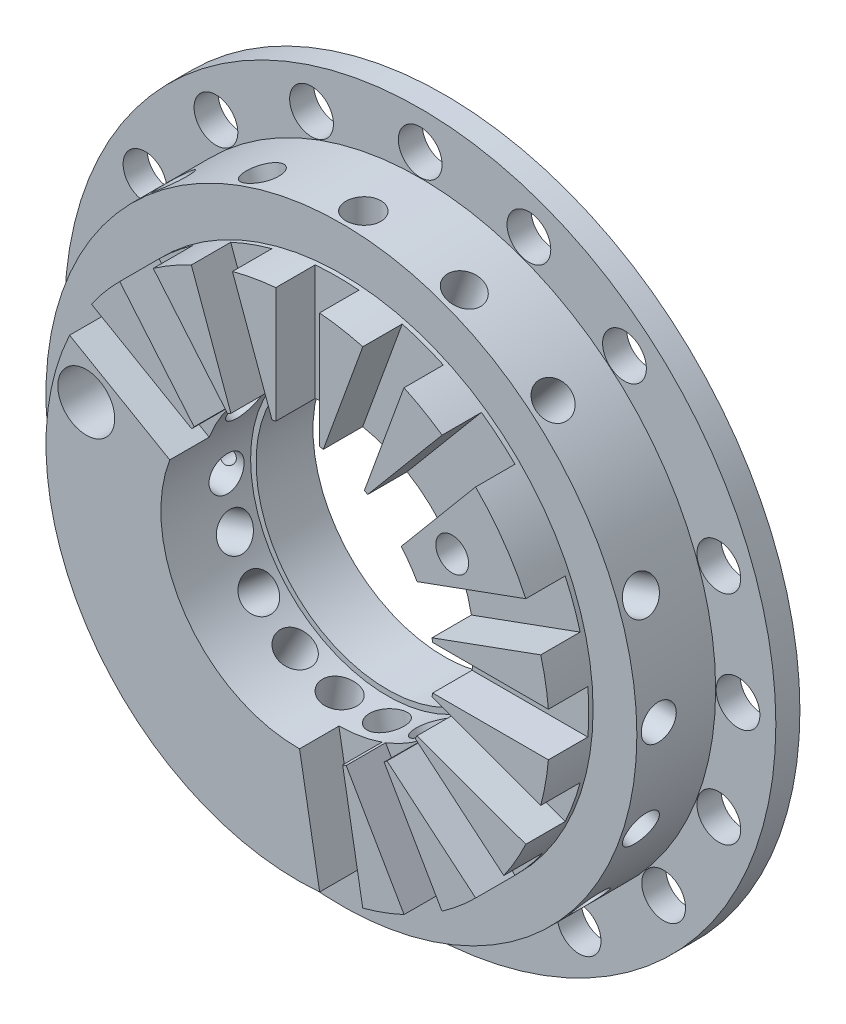
from build123d import *

# Parameters (mm, degrees)
SKETCH1_R                       = 16.25
BOSS_EXTRUDE1_DEPTH             = 6.7
SKETCH2_OUTSIDE_W               = 43.79
SKETCH2_OUTSIDE_H               = 43.79
SKETCH2_OUTSIDE_R               = 13.5
CUT_EXTRUDE1_DEPTH              = 5.6
SKETCH3_OUTSIDE_W               = 43.79
SKETCH3_OUTSIDE_H               = 43.79
SKETCH3_OUTSIDE_R               = 11.5
CUT_EXTRUDE2_DEPTH              = 2
SKETCH4_R                       = 6
CUT_EXTRUDE3_DEPTH              = 24.937731722
SKETCH5_R                       = 6.25
CUT_EXTRUDE4_DEPTH              = 4.1
F_2_0_2_DIAMETER_HOLE1_D        = 2
CUT_EXTRUDE5_DEPTH              = 1.8
CIRPATTERN1_COUNT               = 6
CIRPATTERN1_ANGLE               = 100
CUT_EXTRUDE6_DEPTH              = 1.8
CIRPATTERN2_COUNT               = 6
CIRPATTERN2_ANGLE               = 100
F_1_6_1_6_DIAMETER_HOLE1_REACH  = 36.223
F_1_6_1_6_DIAMETER_HOLE1_BORE_R = 0.8
CIRPATTERN3_COUNT               = 11
CIRPATTERN3_ANGLE               = 200
F_1_6_1_6_DIAMETER_HOLE2_REACH  = 38.494
F_1_6_1_6_DIAMETER_HOLE2_BORE_R = 0.8
CIRPATTERN4_COUNT               = 6
CIRPATTERN4_ANGLE               = 100
F_2_6_2_6_DIAMETER_HOLE1_D      = 2.6
F_1_5_1_5_DIAMETER_HOLE1_D      = 1.5
F_0_8_0_8_DIAMETER_HOLE1_REACH  = 25.938
F_0_8_0_8_DIAMETER_HOLE1_BORE_R = 0.4


with BuildPart() as part:
    # Sketch1 → Boss-Extrude1 (new body)
    with BuildSketch(Plane.XY):
        Circle(SKETCH1_R)
    extrude(amount=BOSS_EXTRUDE1_DEPTH)

    # Sketch2 outside → Cut-Extrude1 (cut)
    with BuildSketch(Plane.XY.offset(6.7)):
        Rectangle(SKETCH2_OUTSIDE_W, SKETCH2_OUTSIDE_H)
        Circle(SKETCH2_OUTSIDE_R, mode=Mode.SUBTRACT)
    extrude(amount=-CUT_EXTRUDE1_DEPTH, mode=Mode.SUBTRACT)

    # Sketch3 outside → Cut-Extrude2 (cut)
    with BuildSketch(Plane.XY.offset(6.7)):
        Rectangle(SKETCH3_OUTSIDE_W, SKETCH3_OUTSIDE_H)
        Circle(SKETCH3_OUTSIDE_R, mode=Mode.SUBTRACT)
    extrude(amount=-CUT_EXTRUDE2_DEPTH, mode=Mode.SUBTRACT)

    # Sketch4 → Cut-Extrude3 (cut, through all)
    with BuildSketch(Plane.XY.offset(6.7)):
        Circle(SKETCH4_R)
    extrude(amount=-CUT_EXTRUDE3_DEPTH, mode=Mode.SUBTRACT)

    # Sketch5 → Cut-Extrude4 (cut)
    with BuildSketch(Plane.XY.offset(6.7)):
        Circle(SKETCH5_R)
    extrude(amount=-CUT_EXTRUDE4_DEPTH, mode=Mode.SUBTRACT)

    # Ø2.0 (2) Diameter Hole1 (through all)
    with Locations(Plane.XY.offset(1.1)):
        with Locations((-9.333276093, 11.122965314), (-4.966132481, 13.644336854), (0, 14.52), (4.966132481, 13.644336854), (9.333276093, 11.122965314), (-13.644336854, -4.966132481), (-11.122965314, -9.333276093), (-7.26, -12.574688863), (-2.52137154, -14.299408574), (2.52137154, -14.299408574), (7.26, -12.574688863), (11.122965314, -9.333276093), (14.52, 0), (13.644336854, 4.966132481), (-14.52, 0), (-12.574688863, 7.26), (13.644336854, -4.966132481)):
            Hole(F_2_0_2_DIAMETER_HOLE1_D / 2)

    # Sketch11 → Cut-Extrude5 (cut)
    with BuildSketch(Plane.XY.offset(6.7)):
        with BuildLine():
            Line((-4.842927568, 3.950766074), (-9.421567416, 6.594245022))
            ThreePointArc((-9.421567416, 6.594245022), (-9.959292144, 5.75), (-10.421567416, 4.862194215))
            Line((-10.421567416, 4.862194215), (-5.842927568, 2.218715266))
            ThreePointArc((-5.842927568, 2.218715266), (-5.412658774, 3.125), (-4.842927568, 3.950766074))
        make_face()
    cut_extrude5 = extrude(amount=-CUT_EXTRUDE5_DEPTH, mode=Mode.SUBTRACT)

    # CirPattern1: Cut-Extrude5 ×6 about axis
    cirpattern1_axis = Axis((0, 0, 0), (0, 0, -1))
    for i in range(1, CIRPATTERN1_COUNT):
        add(cut_extrude5.rotate(cirpattern1_axis, i * CIRPATTERN1_ANGLE / (CIRPATTERN1_COUNT - 1)), mode=Mode.SUBTRACT)

    # Sketch12 → Cut-Extrude6 (cut)
    with BuildSketch(Plane.XY.offset(6.7)):
        with BuildLine():
            Line((6.139436232, 1.170394271), (11.107551555, 2.978640369))
            ThreePointArc((11.107551555, 2.978640369), (10.806465139, 3.933231648), (10.423511269, 4.858025611))
            Line((10.423511269, 4.858025611), (5.455395946, 3.049779513))
            ThreePointArc((5.455395946, 3.049779513), (5.87307888, 2.137625896), (6.139436232, 1.170394271))
        make_face()
    cut_extrude6 = extrude(amount=-CUT_EXTRUDE6_DEPTH, mode=Mode.SUBTRACT)

    # CirPattern2: Cut-Extrude6 ×6 about axis
    cirpattern2_axis = Axis((0, 0, 0), (0, 0, -1))
    for i in range(1, CIRPATTERN2_COUNT):
        add(cut_extrude6.rotate(cirpattern2_axis, i * CIRPATTERN2_ANGLE / (CIRPATTERN2_COUNT - 1)), mode=Mode.SUBTRACT)

    # Ø1.6 (1.6) Diameter Hole1 bore → Ø1.6 (1.6) Diameter Hole1 (cut, up to next)
    with BuildSketch(Plane(origin=(-13.5, 0, 4.7), x_dir=(0, 0, 1), z_dir=(-1, 0, 0)), mode=Mode.PRIVATE) as f_1_6_1_6_diameter_hole1_sk1:
        with Locations((-1, 0)):
            Circle(F_1_6_1_6_DIAMETER_HOLE1_BORE_R)
    f_1_6_1_6_diameter_hole1_tool1 = extrude(f_1_6_1_6_diameter_hole1_sk1.sketch, amount=-F_1_6_1_6_DIAMETER_HOLE1_REACH, mode=Mode.PRIVATE) & part.part
    f_1_6_1_6_diameter_hole1 = f_1_6_1_6_diameter_hole1_tool1.solids().sort_by_distance((-13.5, 0, 3.7))[0]
    add(f_1_6_1_6_diameter_hole1, mode=Mode.SUBTRACT)

    # CirPattern3: Ø1.6 (1.6) Diameter Hole1 ×11 about axis
    cirpattern3_axis = Axis((0, 0, 4.7), (0, 0, 1))
    for i in range(1, CIRPATTERN3_COUNT):
        add(f_1_6_1_6_diameter_hole1.rotate(cirpattern3_axis, i * CIRPATTERN3_ANGLE / (CIRPATTERN3_COUNT - 1)), mode=Mode.SUBTRACT)

    # Ø1.6 (1.6) Diameter Hole2 bore → Ø1.6 (1.6) Diameter Hole2 (cut, up to next)
    with BuildSketch(Plane(origin=(-11.691342951, 6.75, 4.7), x_dir=(0, 0, 1), z_dir=(-0.8660254037844386, 0.5000000000000003, 0)), mode=Mode.PRIVATE) as f_1_6_1_6_diameter_hole2_sk1:
        with Locations((-1, 0)):
            Circle(F_1_6_1_6_DIAMETER_HOLE2_BORE_R)
    f_1_6_1_6_diameter_hole2_tool1 = extrude(f_1_6_1_6_diameter_hole2_sk1.sketch, amount=-F_1_6_1_6_DIAMETER_HOLE2_REACH, mode=Mode.PRIVATE) & part.part
    f_1_6_1_6_diameter_hole2 = f_1_6_1_6_diameter_hole2_tool1.solids().sort_by_distance((-11.691343, 6.75, 3.7))[0]
    add(f_1_6_1_6_diameter_hole2, mode=Mode.SUBTRACT)

    # CirPattern4: Ø1.6 (1.6) Diameter Hole2 ×6 about axis
    cirpattern4_axis = Axis((0, 0, 4.7), (0, 0, -1))
    for i in range(1, CIRPATTERN4_COUNT):
        add(f_1_6_1_6_diameter_hole2.rotate(cirpattern4_axis, i * CIRPATTERN4_ANGLE / (CIRPATTERN4_COUNT - 1)), mode=Mode.SUBTRACT)

    # Ø2.6 (2.6) Diameter Hole1 (through all)
    with Locations(Plane.XY.offset(6.7)):
        with Locations((-9.659258263, 2.588190451)):
            Hole(F_2_6_2_6_DIAMETER_HOLE1_D / 2)

    # Ø1.5 (1.5) Diameter Hole1 (through all)
    with Locations(Plane.XY.offset(6.7)):
        with Locations((7.061090622, 4.944228881)):
            Hole(F_1_5_1_5_DIAMETER_HOLE1_D / 2)

    # Ø0.8 (0.8) Diameter Hole1 bore → Ø0.8 (0.8) Diameter Hole1 (cut, up to next)
    with BuildSketch(Plane(origin=(0, 0, 0), x_dir=(-1, 0, 0), z_dir=(0, 0, -1)), mode=Mode.PRIVATE) as f_0_8_0_8_diameter_hole1_sk1:
        with Locations((-7, 0)):
            Circle(F_0_8_0_8_DIAMETER_HOLE1_BORE_R)
    f_0_8_0_8_diameter_hole1_tool1 = extrude(f_0_8_0_8_diameter_hole1_sk1.sketch, amount=-F_0_8_0_8_DIAMETER_HOLE1_REACH, mode=Mode.PRIVATE) & part.part
    # Ø0.8 (0.8) Diameter Hole1 bore → Ø0.8 (0.8) Diameter Hole1 (cut, up to next)
    with BuildSketch(Plane(origin=(0, 0, 0), x_dir=(-1, 0, 0), z_dir=(0, 0, -1)), mode=Mode.PRIVATE) as f_0_8_0_8_diameter_hole1_sk2:
        with Locations((7, 0)):
            Circle(F_0_8_0_8_DIAMETER_HOLE1_BORE_R)
    f_0_8_0_8_diameter_hole1_tool2 = extrude(f_0_8_0_8_diameter_hole1_sk2.sketch, amount=-F_0_8_0_8_DIAMETER_HOLE1_REACH, mode=Mode.PRIVATE) & part.part
    add(f_0_8_0_8_diameter_hole1_tool1.solids().sort_by_distance((7, 0, 0))[0], mode=Mode.SUBTRACT)
    add(f_0_8_0_8_diameter_hole1_tool2.solids().sort_by_distance((-7, 0, 0))[0], mode=Mode.SUBTRACT)


solid = part.part
